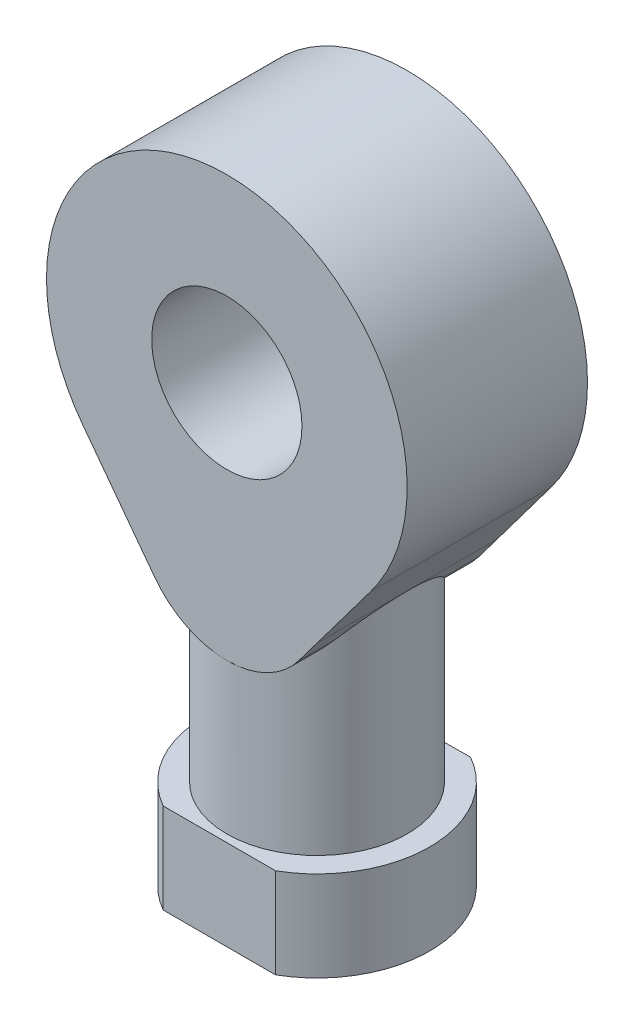
from build123d import *

# Parameters (mm, degrees)
BOSS_EXTRUDE1_DEPTH      = 6
SKETCH3_R                = 6
BOSS_EXTRUDE2_DEPTH      = 14
BOSS_EXTRUDE3_DEPTH      = 6
BOSS_EXTRUDE3_DEPTH_BACK = 6
SKETCH5_R                = 5
CUT_EXTRUDE1_DEPTH       = 48.298702048
SKETCH6_R                = 4.9
CUT_EXTRUDE2_DEPTH       = 20


with BuildPart() as part:
    # Sketch2 → Boss-Extrude1 (new body)
    with BuildSketch(Plane(origin=(0, 0, 0), x_dir=(1, 0, 0), z_dir=(0, 1, 0))):
        with BuildLine():
            Line((-3.80541246, 6.462881402), (3.677540288, 6.536489687))
            ThreePointArc((3.677540288, 6.536489687), (7.499909291, 0.03688665), (3.741657387, -6.5))
            Line((3.741657387, -6.5), (-3.741657387, -6.5))
            ThreePointArc((-3.741657387, -6.5), (-7.499909291, -0.03688665), (-3.80541246, 6.462881402))
        make_face()
    extrude(amount=BOSS_EXTRUDE1_DEPTH)

    # Sketch3 → Boss-Extrude2 (add)
    with BuildSketch(Plane(origin=(0, 6, 0), x_dir=(1, 0, 0), z_dir=(0, 1, 0))):
        Circle(SKETCH3_R)
    extrude(amount=BOSS_EXTRUDE2_DEPTH)

    # Sketch4 → Boss-Extrude3 (add, two sides: drawn at the far end of the back side and taken through both)
    with BuildSketch(Plane.XY.offset(-BOSS_EXTRUDE3_DEPTH_BACK)):
        with BuildLine():
            Line((6, 20), (9.551839137, 24.736029469))
            ThreePointArc((9.551839137, 24.736029469), (0.00015174, 44), (-9.551535656, 24.736029469))
            Line((-9.551535656, 24.736029469), (-6, 20))
            Line((-6, 20), (-4.800072834, 18.400029674))
            ThreePointArc((-4.800072834, 18.400029674), (0, 15.999932561), (4.800072834, 18.400029674))
            Line((4.800072834, 18.400029674), (6, 20))
        make_face()
    extrude(amount=BOSS_EXTRUDE3_DEPTH + BOSS_EXTRUDE3_DEPTH_BACK)

    # Sketch5 → Cut-Extrude1 (cut, through all)
    with BuildSketch(Plane.XY.offset(6)):
        with Locations((0.00015174, 32)):
            Circle(SKETCH5_R)
    extrude(amount=-CUT_EXTRUDE1_DEPTH, mode=Mode.SUBTRACT)

    # Sketch6 → Cut-Extrude2 (cut)
    with BuildSketch(Plane.XZ):
        Circle(SKETCH6_R)
    extrude(amount=-CUT_EXTRUDE2_DEPTH, mode=Mode.SUBTRACT)


solid = part.part
